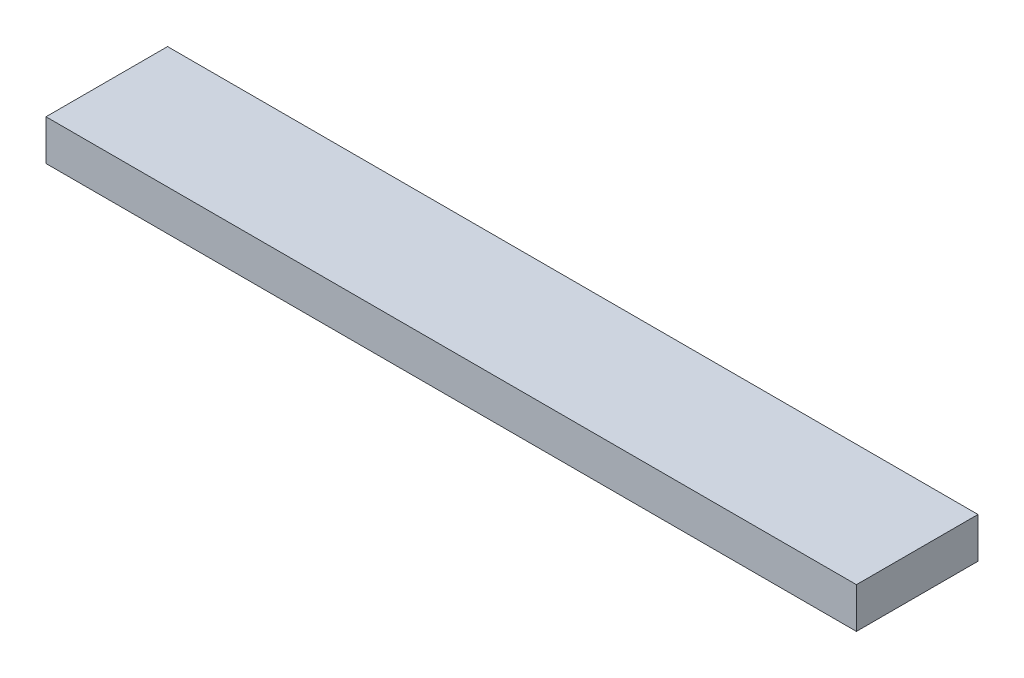
from build123d import *

# Parameters (mm, degrees)
SKETCH1_W           = 200
SKETCH1_H           = 30
BOSS_EXTRUDE1_DEPTH = 10


with BuildPart() as part:
    # Sketch1 → Boss-Extrude1 (new body)
    with BuildSketch(Plane(origin=(0, 0, 0), x_dir=(1, 0, 0), z_dir=(0, 1, 0))):
        with Locations((100, 15)):
            Rectangle(SKETCH1_W, SKETCH1_H)
    extrude(amount=BOSS_EXTRUDE1_DEPTH)


solid = part.part
